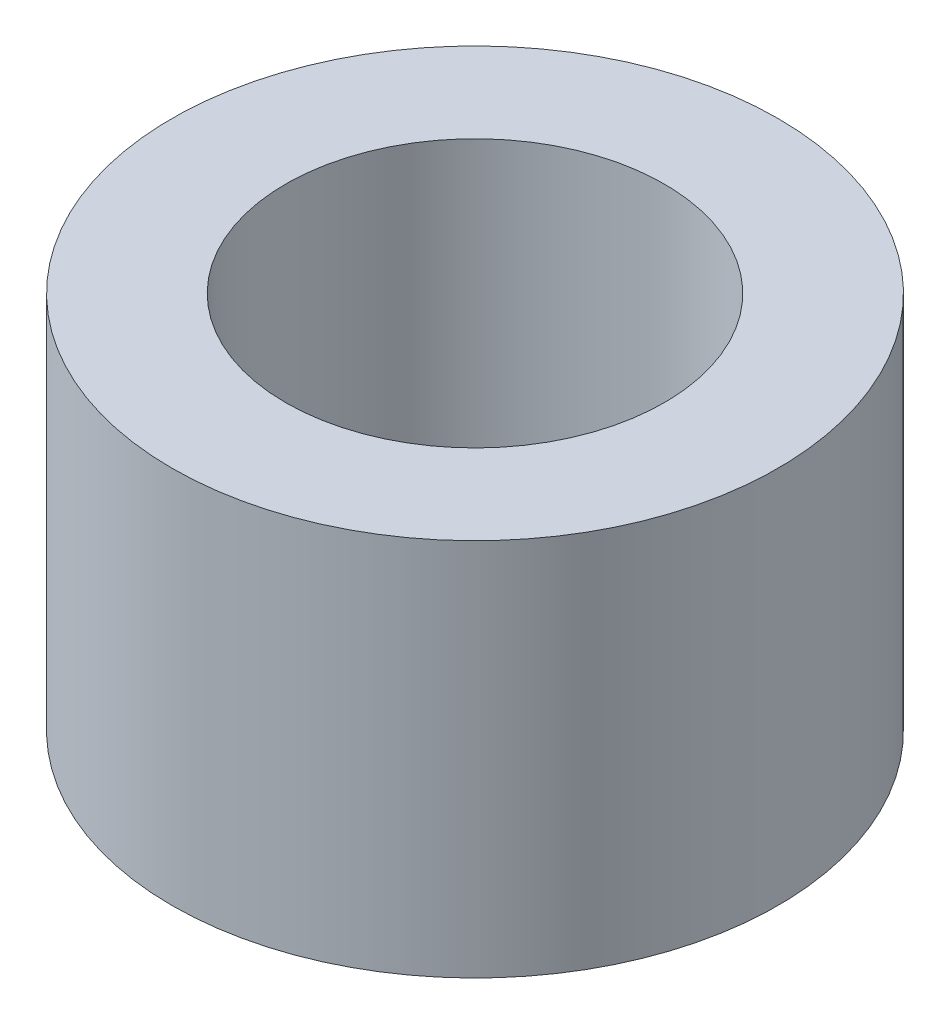
from build123d import *

# Parameters (mm, degrees)
SKETCH1_R      = 1
SKETCH1_R_2    = 0.625
EXTRUDE1_DEPTH = 0.625


with BuildPart() as part:
    # Sketch1 → Extrude1 (new body, symmetric)
    with BuildSketch(Plane(origin=(0, 0, 0), x_dir=(1, 0, 0), z_dir=(0, 1, 0))):
        with Locations(Location((0, 0, 0), (0, 0, 270))):  # turned: the seam where the file's is
            Circle(SKETCH1_R)
        with Locations(Location((0, 0, 0), (0, 0, 270))):  # turned: the seam where the file's is
            Circle(SKETCH1_R_2, mode=Mode.SUBTRACT)
    extrude(amount=EXTRUDE1_DEPTH, both=True)


solid = part.part
